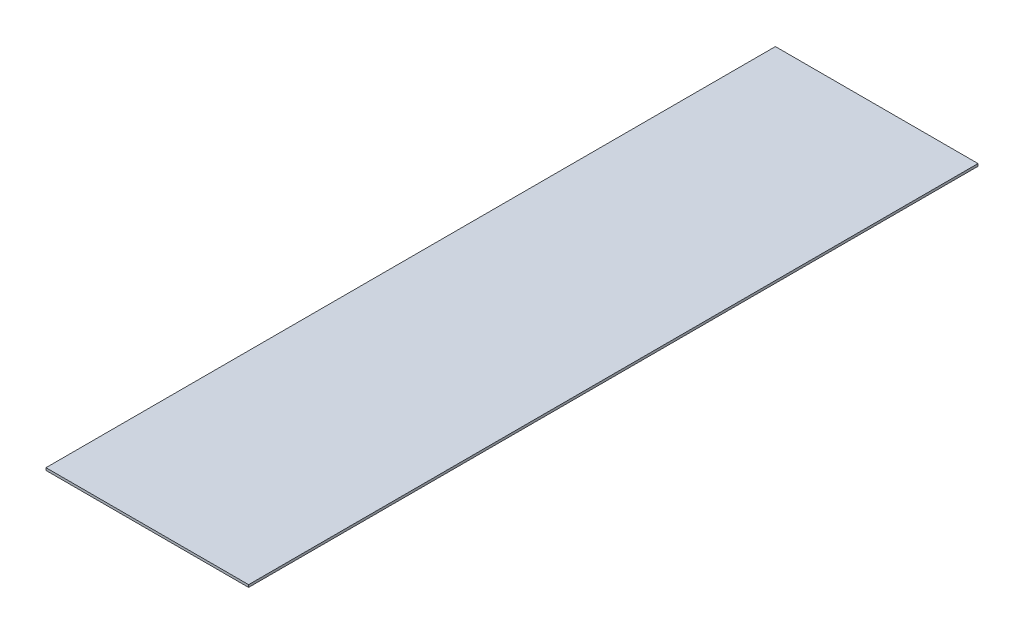
from build123d import *

# Parameters (mm, degrees)
SKETCH_1_W      = 250
SKETCH_1_H      = 3
EXTRUDE_1_DEPTH = 900


with BuildPart() as part:
    # 스케치1 → 보스-돌출1 (new body)
    with BuildSketch(Plane.XY):
        with Locations((125, 1.5)):
            Rectangle(SKETCH_1_W, SKETCH_1_H)
    extrude(amount=EXTRUDE_1_DEPTH)


solid = part.part
